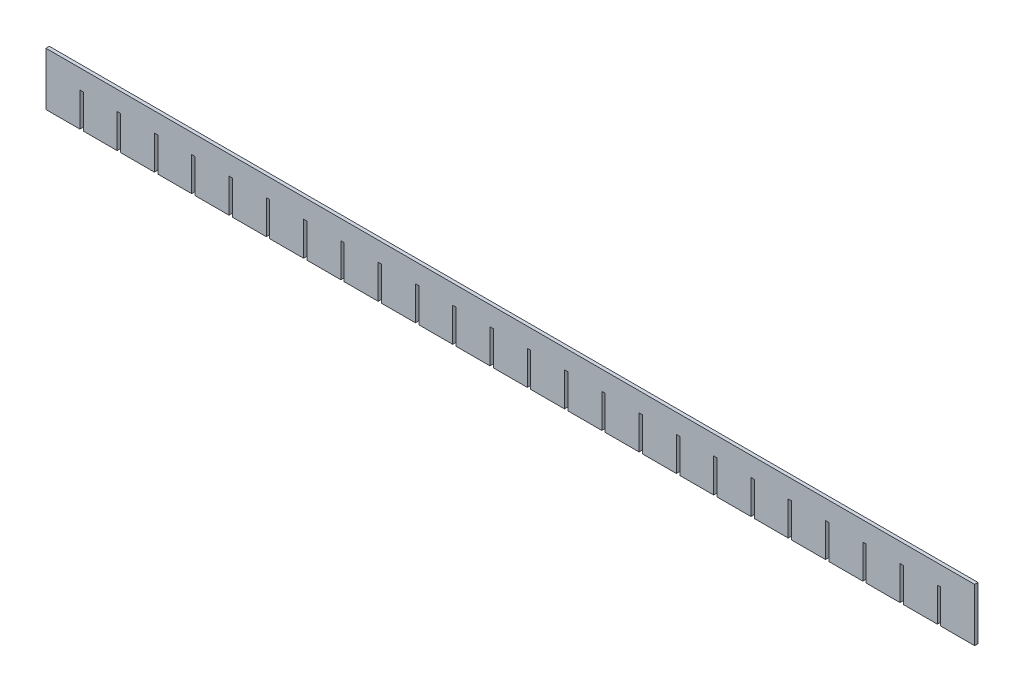
from build123d import *

# Parameters (mm, degrees)
SKETCH1_W           = 822
SKETCH1_H           = 47
BOSS_EXTRUDE1_DEPTH = 3
SKETCH2_W           = 3
SKETCH2_H           = 30
CUT_EXTRUDE1_DEPTH  = 4
LPATTERN1_COUNT     = 24
LPATTERN1_PITCH     = 33


with BuildPart() as part:
    # Sketch1 → Boss-Extrude1 (new body)
    with BuildSketch(Plane.XY):
        Rectangle(SKETCH1_W, SKETCH1_H)
    extrude(amount=BOSS_EXTRUDE1_DEPTH)

    # Sketch2 → Cut-Extrude1 (cut, through all)
    with BuildSketch(Plane.XY.offset(3)):
        with Locations((-379.5, -8.5)):
            Rectangle(SKETCH2_W, SKETCH2_H)
    cut_extrude1 = extrude(amount=-CUT_EXTRUDE1_DEPTH, mode=Mode.SUBTRACT)

    # LPattern1: Cut-Extrude1 ×24
    with Locations(*[(i * LPATTERN1_PITCH, 0, 0) for i in range(1, LPATTERN1_COUNT)]):
        add(cut_extrude1, mode=Mode.SUBTRACT)


solid = part.part
